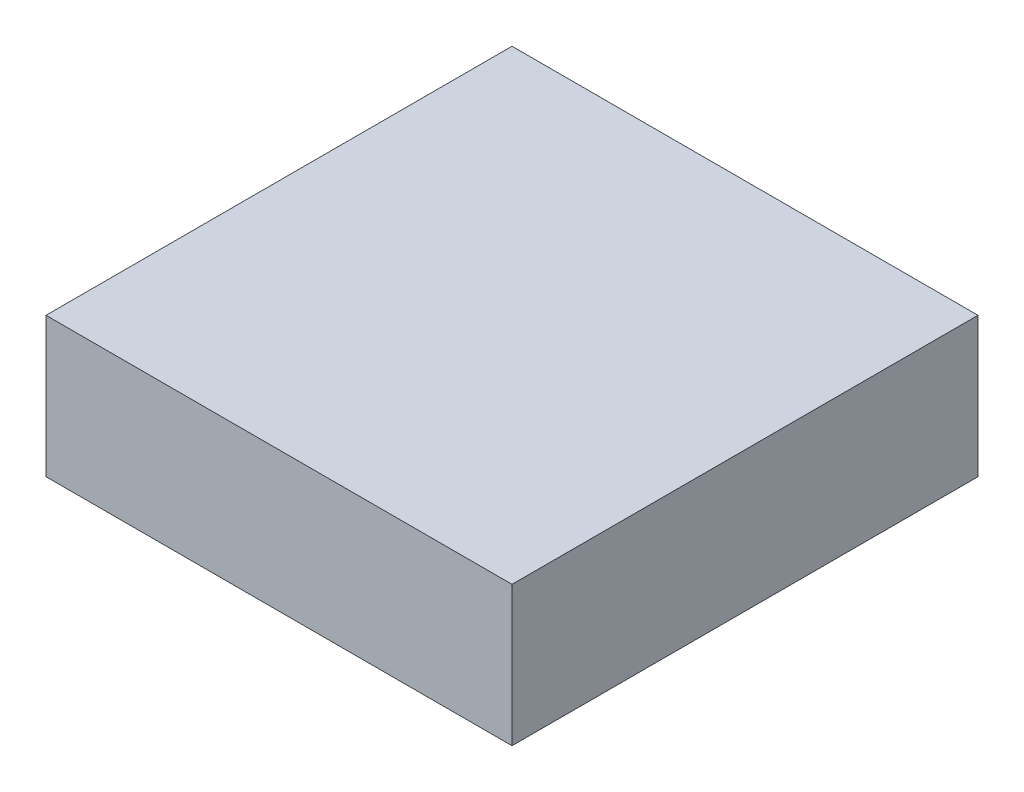
from build123d import *

# Parameters (mm, degrees)
SKETCH1_W           = 127
SKETCH1_H           = 127
BOSS_EXTRUDE1_DEPTH = 38.1


with BuildPart() as part:
    # Sketch1 → Boss-Extrude1 (new body)
    with BuildSketch(Plane(origin=(0, 0, 0), x_dir=(1, 0, 0), z_dir=(0, 1, 0))):
        with Locations((63.5, 63.5)):
            Rectangle(SKETCH1_W, SKETCH1_H)
    extrude(amount=BOSS_EXTRUDE1_DEPTH)


solid = part.part
